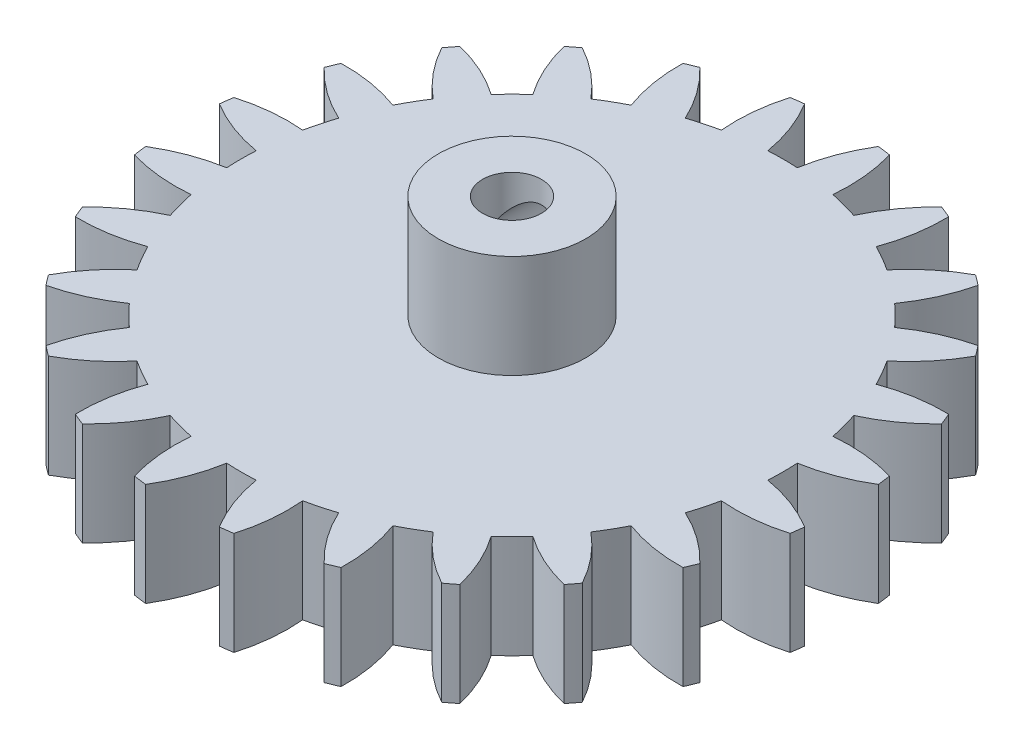
from build123d import *

# Parameters (mm, degrees)
SKETCH1_R           = 22.5
BOSS_EXTRUDE1_DEPTH = 7
CUT_EXTRUDE1_DEPTH  = 8
CIRPATTERN1_COUNT   = 24
SKETCH3_R           = 5
BOSS_EXTRUDE2_DEPTH = 7
SKETCH4_R           = 2
CUT_EXTRUDE2_DEPTH  = 15
SKETCH5_R           = 2
CUT_EXTRUDE3_DEPTH  = 23.360679775


with BuildPart() as part:
    # Sketch1 → Boss-Extrude1 (new body)
    with BuildSketch(Plane(origin=(0, 0, 0), x_dir=(1, 0, 0), z_dir=(0, 1, 0))):
        Circle(SKETCH1_R)
    extrude(amount=BOSS_EXTRUDE1_DEPTH)

    # Sketch2 → Cut-Extrude1 (cut, through all)
    with BuildSketch(Plane(origin=(0, 7, 0), x_dir=(1, 0, 0), z_dir=(0, 1, 0))):
        with BuildLine():
            ThreePointArc((2.5, 22.360679775), (1.560955546, 20.431571445), (1, 18.360679775))
            ThreePointArc((1, 18.360679775), (0, 18.387891717), (-1, 18.360679775))
            ThreePointArc((-1, 18.360679775), (-1.560955546, 20.431571445), (-2.5, 22.360679775))
            ThreePointArc((-2.5, 22.360679775), (0, 22.5), (2.5, 22.360679775))
        make_face()
    cut_extrude1 = extrude(amount=-CUT_EXTRUDE1_DEPTH, mode=Mode.SUBTRACT)

    # CirPattern1: Cut-Extrude1 ×24 about axis
    cirpattern1_axis = Axis((0, 0, 0), (0, 1, 0))
    for i in range(1, CIRPATTERN1_COUNT):
        add(cut_extrude1.rotate(cirpattern1_axis, i * 360 / CIRPATTERN1_COUNT), mode=Mode.SUBTRACT)

    # Sketch3 → Boss-Extrude2 (add)
    with BuildSketch(Plane(origin=(0, 7, 0), x_dir=(1, 0, 0), z_dir=(0, 1, 0))):
        Circle(SKETCH3_R)
    extrude(amount=BOSS_EXTRUDE2_DEPTH)

    # Sketch4 → Cut-Extrude2 (cut, through all)
    with BuildSketch(Plane(origin=(0, 14, 0), x_dir=(1, 0, 0), z_dir=(0, 1, 0))):
        Circle(SKETCH4_R)
    extrude(amount=-CUT_EXTRUDE2_DEPTH, mode=Mode.SUBTRACT)

    # Sketch5 → Cut-Extrude3 (cut, through all)
    with BuildSketch(Plane.XY):
        with Locations((0, 10.5)):
            Circle(SKETCH5_R)
    extrude(amount=-CUT_EXTRUDE3_DEPTH, mode=Mode.SUBTRACT)


solid = part.part
